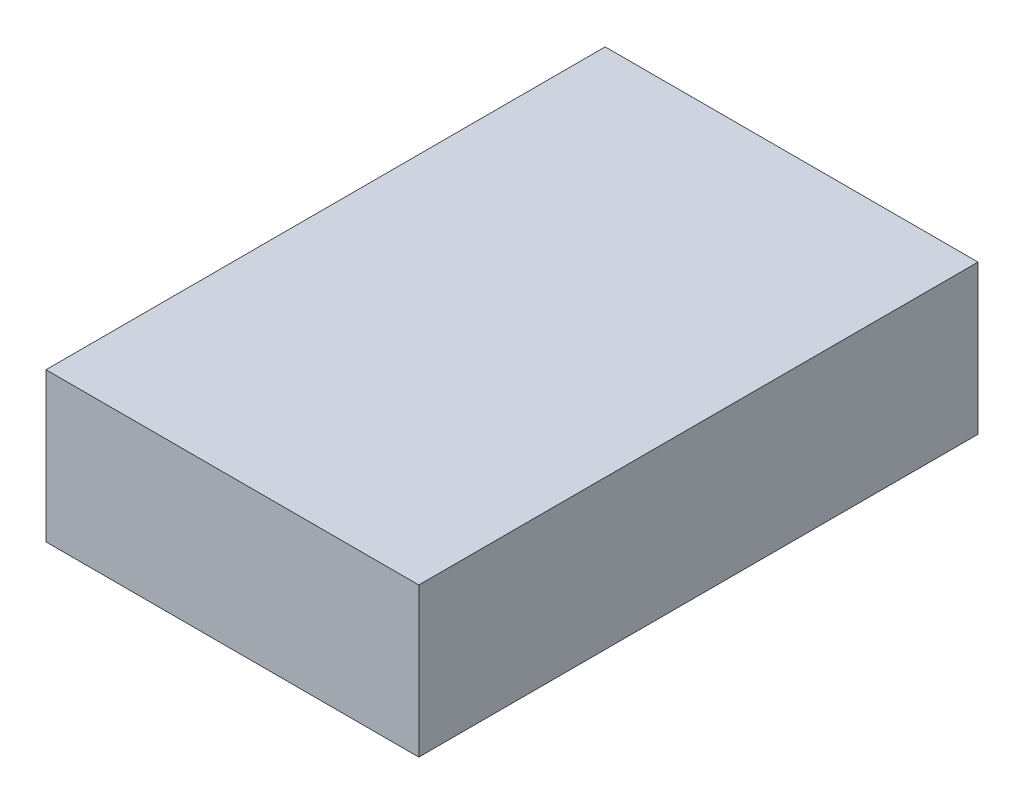
from build123d import *

# Parameters (mm, degrees)
BASES_W    = 2
BASES_H    = 3
BASE_DEPTH = 0.8


with BuildPart() as part:
    # BaseS → Base (new body)
    with BuildSketch(Plane(origin=(0, 0, 0), x_dir=(1, 0, 0), z_dir=(0, 1, 0))):
        Rectangle(BASES_W, BASES_H)
    extrude(amount=BASE_DEPTH)


solid = part.part
